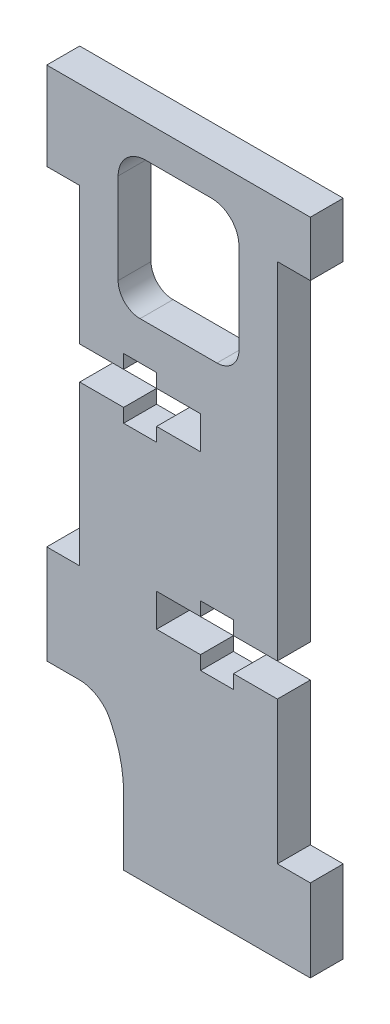
from build123d import *

# Parameters (mm, degrees)
BOSS_EXTRUDE1_DEPTH = 3


with BuildPart() as part:
    # Model → Boss-Extrude1 (new body)
    with BuildSketch(Plane.XY):
        with BuildLine():
            Line((71, 68), (71, 63))
            Line((71, 63), (68, 63))
            Line((68, 63), (68, 31.5))
            Line((68, 31.5), (64, 31.5))
            Line((64, 31.5), (64, 32.75))
            Line((64, 32.75), (61, 32.75))
            Line((61, 32.75), (61, 31.5))
            Line((61, 31.5), (57, 31.5))
            Line((57, 31.5), (57, 28.5))
            Line((57, 28.5), (61, 28.5))
            Line((61, 28.5), (61, 27.25))
            Line((61, 27.25), (64, 27.25))
            Line((64, 27.25), (64, 28.5))
            Line((64, 28.5), (68, 28.5))
            Line((68, 28.5), (68, 15.5))
            Line((68, 15.5), (71, 15.5))
            Line((71, 15.5), (71, 8))
            Line((71, 8), (54, 8))
            Line((54, 8), (54, 14))
            ThreePointArc((54, 14), (53.719770148, 16.588625278), (52.861029282, 19.046688281))
            ThreePointArc((52.861029282, 19.046688281), (51.73197083, 20.444193402), (50.0235, 21))
            Line((50.0235, 21), (47, 21))
            Line((47, 21), (47, 30))
            Line((47, 30), (50, 30))
            Line((50, 30), (50, 44.5))
            Line((50, 44.5), (54, 44.5))
            Line((54, 44.5), (54, 43.25))
            Line((54, 43.25), (57, 43.25))
            Line((57, 43.25), (57, 44.5))
            Line((57, 44.5), (61, 44.5))
            Line((61, 44.5), (61, 47.5))
            Line((61, 47.5), (57, 47.5))
            Line((57, 47.5), (57, 48.75))
            Line((57, 48.75), (54, 48.75))
            Line((54, 48.75), (54, 47.5))
            Line((54, 47.5), (50, 47.5))
            Line((50, 47.5), (50, 60))
            Line((50, 60), (47, 60))
            Line((47, 60), (47, 68))
            Line((47, 68), (71, 68))
        make_face()
        with BuildLine():
            Line((56, 65), (62, 65))
            ThreePointArc((62, 65), (63.76778125, 64.26778125), (64.5, 62.5))
            Line((64.5, 62.5), (64.5, 54.25))
            ThreePointArc((64.5, 54.25), (63.914214645, 52.835814644), (62.5, 52.2501))
            Line((62.5, 52.2501), (55.5, 52.2501))
            ThreePointArc((55.5, 52.2501), (54.085735358, 52.835764643), (53.5, 54.25))
            Line((53.5, 54.25), (53.5, 62.5))
            ThreePointArc((53.5, 62.5), (54.2322, 64.2678), (56, 65))
        make_face(mode=Mode.SUBTRACT)
    extrude(amount=BOSS_EXTRUDE1_DEPTH)


solid = part.part
